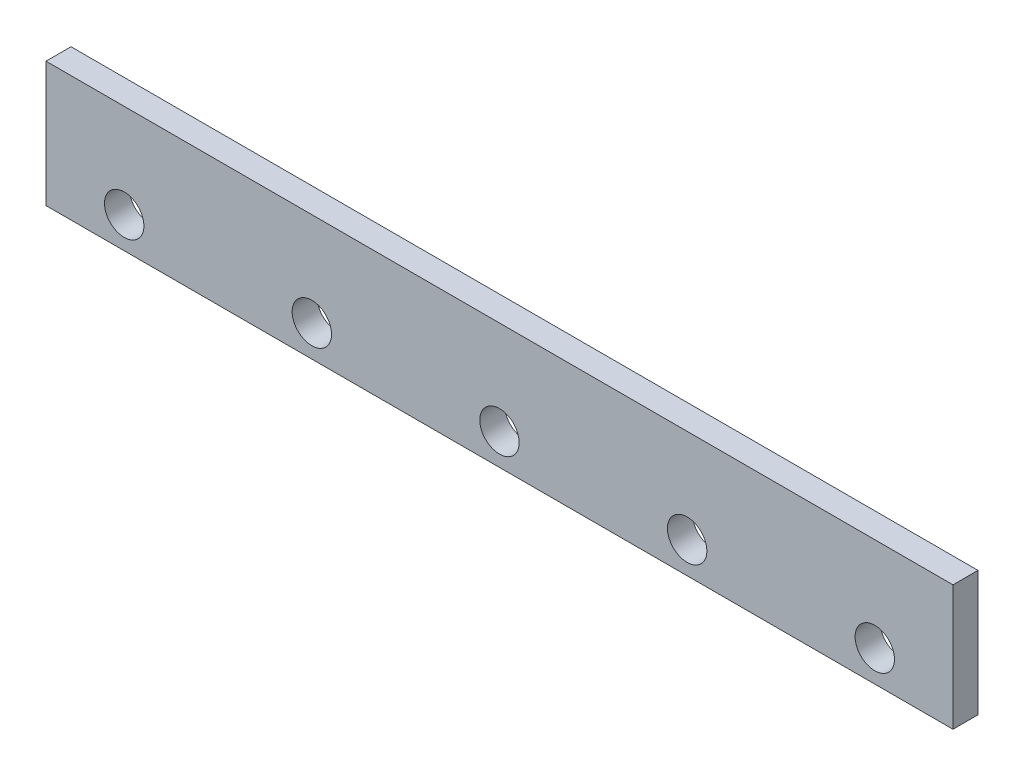
from build123d import *

# Parameters (mm, degrees)
CROQUIS1_W              = 580
CROQUIS1_H              = 80
CROQUIS1_R              = 12.6
SALIENTE_EXTRUIR1_DEPTH = 16


with BuildPart() as part:
    # Croquis1 → Saliente-Extruir1 (new body)
    with BuildSketch(Plane.XY):
        Rectangle(CROQUIS1_W, CROQUIS1_H)
        with Locations((-240, -20)):
            Circle(CROQUIS1_R, mode=Mode.SUBTRACT)
        with Locations((-120, -20)):
            Circle(CROQUIS1_R, mode=Mode.SUBTRACT)
        with Locations((0, -20)):
            Circle(CROQUIS1_R, mode=Mode.SUBTRACT)
        with Locations((120, -20)):
            Circle(CROQUIS1_R, mode=Mode.SUBTRACT)
        with Locations((240, -20)):
            Circle(CROQUIS1_R, mode=Mode.SUBTRACT)
    extrude(amount=-SALIENTE_EXTRUIR1_DEPTH)


solid = part.part
